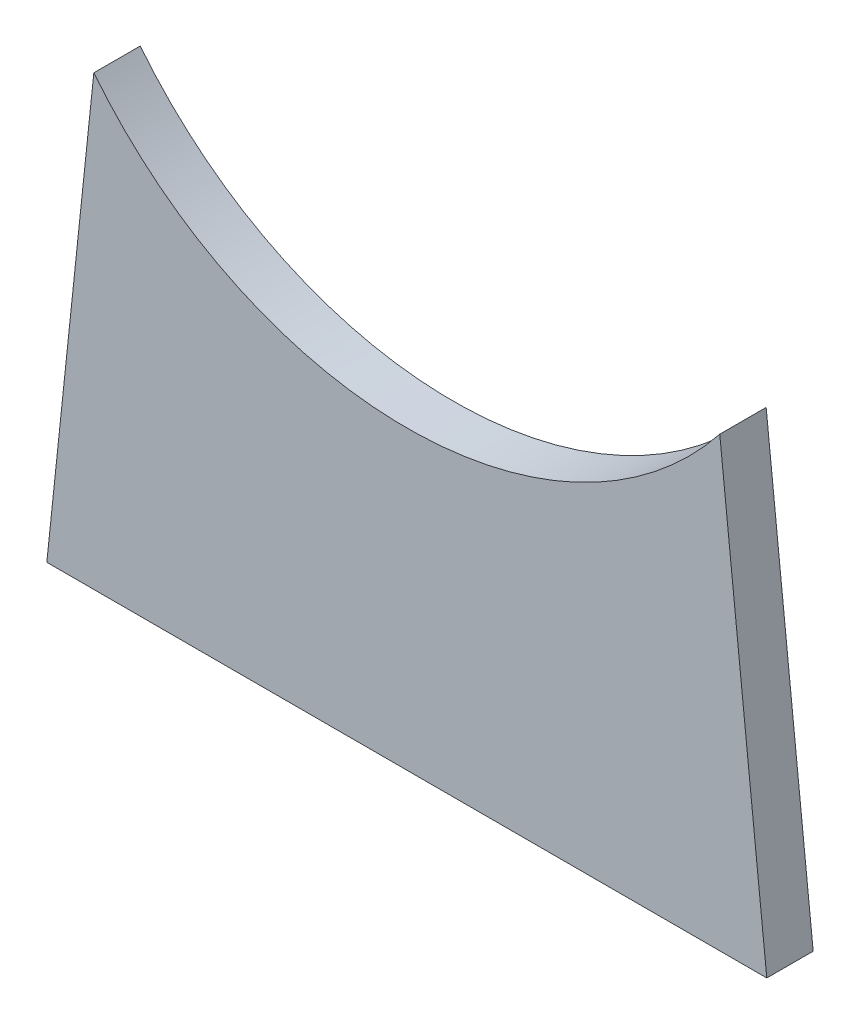
from build123d import *

# Parameters (mm, degrees)
BOSS_EXTRUDE1_DEPTH = 127.5


with BuildPart() as part:
    # Sketch1 → Boss-Extrude1 (new body, symmetric)
    with BuildSketch(Plane.XY):
        with BuildLine():
            Line((-1978.13, 0), (1978.13, 0))
            Line((1978.13, 0), (1719.704961541, 2458.75))
            ThreePointArc((1719.704961541, 2458.75), (0, 1628.423481588), (-1719.704961541, 2458.75))
            Line((-1719.704961541, 2458.75), (-1978.13, 0))
        make_face()
    extrude(amount=BOSS_EXTRUDE1_DEPTH, both=True)


solid = part.part
